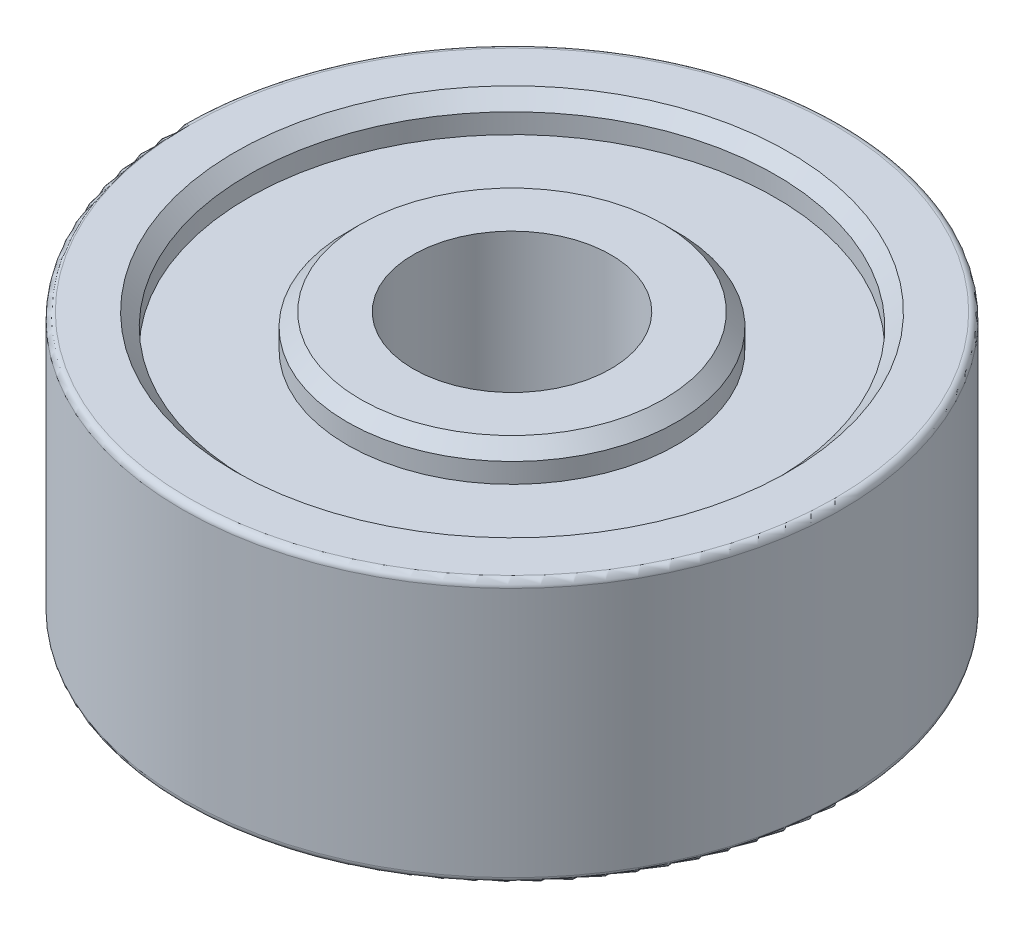
from build123d import *

# Parameters (mm, degrees)
SKETCH2_R           = 5
SKETCH2_R_2         = 1.5
BOSS_EXTRUDE1_DEPTH = 2
SKETCH3_R           = 4
SKETCH3_R_2         = 2.5
CUT_EXTRUDE1_DEPTH  = 0.5
CHAMFER1_SIZE       = 0.2
FILLET1_R           = 0.1


with BuildPart() as part:
    # Sketch2 → Boss-Extrude1 (new body, symmetric)
    with BuildSketch(Plane(origin=(0, 0, 0), x_dir=(1, 0, 0), z_dir=(0, 1, 0))):
        Circle(SKETCH2_R)
        Circle(SKETCH2_R_2, mode=Mode.SUBTRACT)
    extrude(amount=BOSS_EXTRUDE1_DEPTH, both=True)

    # Sketch3 → Cut-Extrude1 (cut)
    with BuildSketch(Plane(origin=(0, 2, 0), x_dir=(1, 0, 0), z_dir=(0, 1, 0))):
        Circle(SKETCH3_R)
        Circle(SKETCH3_R_2, mode=Mode.SUBTRACT)
    cut_extrude1 = extrude(amount=-CUT_EXTRUDE1_DEPTH, mode=Mode.SUBTRACT)

    # Mirror1: Cut-Extrude1 across plane
    add(cut_extrude1.mirror(Plane.ZX), mode=Mode.SUBTRACT)

    # Chamfer1
    chamfer1_edges = [part.edges().sort_by_distance(p)[0] for p in [
        (-4, 2, 0),
        (-2.5, 2, 0),
        (-2.5, -2, 0),
        (-4, -2, 0),
    ]]
    chamfer(chamfer1_edges, length=CHAMFER1_SIZE)

    # Fillet1
    fillet1_edges = [part.edges().sort_by_distance(p)[0] for p in [
        (-5, -2, 0),
        (-5, 2, 0),
    ]]
    fillet(fillet1_edges, radius=FILLET1_R)


solid = part.part
